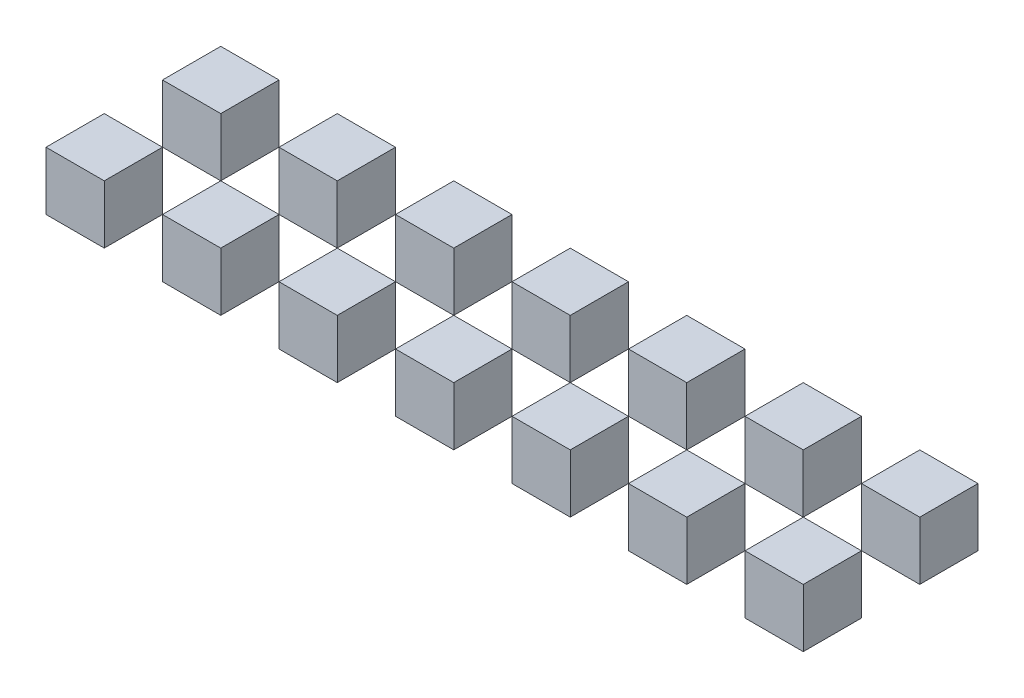
from build123d import *

# Parameters (mm, degrees)
SKETCH1_W              = 25.4
SKETCH1_H              = 25.4
BOSS_EXTRUDE1_DEPTH    = 25.4
BOSS_EXTRUDE1_2_DEPTH  = 25.4
BOSS_EXTRUDE1_3_DEPTH  = 25.4
BOSS_EXTRUDE1_4_DEPTH  = 25.4
BOSS_EXTRUDE1_5_DEPTH  = 25.4
BOSS_EXTRUDE1_6_DEPTH  = 25.4
BOSS_EXTRUDE1_7_DEPTH  = 25.4
BOSS_EXTRUDE1_8_DEPTH  = 25.4
BOSS_EXTRUDE1_9_DEPTH  = 25.4
BOSS_EXTRUDE1_10_DEPTH = 25.4
BOSS_EXTRUDE1_11_DEPTH = 25.4
BOSS_EXTRUDE1_12_DEPTH = 25.4
BOSS_EXTRUDE1_13_DEPTH = 25.4
BOSS_EXTRUDE1_14_DEPTH = 25.4


with BuildPart() as part:
    # Sketch1 → Boss-Extrude1 (new body)
    with BuildSketch(Plane(origin=(0, 0, 0), x_dir=(1, 0, 0), z_dir=(0, 1, 0))):
        with Locations((38.1, 12.7)):
            Rectangle(SKETCH1_W, SKETCH1_H)
    extrude(amount=BOSS_EXTRUDE1_DEPTH)


with BuildPart() as body_2:
    # Sketch1 → Boss-Extrude1 2 (new body)
    with BuildSketch(Plane(origin=(0, 0, 0), x_dir=(1, 0, 0), z_dir=(0, 1, 0))):
        with Locations((-12.7, 12.7)):
            Rectangle(SKETCH1_W, SKETCH1_H)
    extrude(amount=BOSS_EXTRUDE1_2_DEPTH)


with BuildPart() as body_3:
    # Sketch1 → Boss-Extrude1 3 (new body)
    with BuildSketch(Plane(origin=(0, 0, 0), x_dir=(1, 0, 0), z_dir=(0, 1, 0))):
        with Locations((88.9, 12.7)):
            Rectangle(SKETCH1_W, SKETCH1_H)
    extrude(amount=BOSS_EXTRUDE1_3_DEPTH)


with BuildPart() as body_4:
    # Sketch1 → Boss-Extrude1 4 (new body)
    with BuildSketch(Plane(origin=(0, 0, 0), x_dir=(1, 0, 0), z_dir=(0, 1, 0))):
        with Locations((139.7, 12.7)):
            Rectangle(SKETCH1_W, SKETCH1_H)
    extrude(amount=BOSS_EXTRUDE1_4_DEPTH)


with BuildPart() as body_5:
    # Sketch1 → Boss-Extrude1 5 (new body)
    with BuildSketch(Plane(origin=(0, 0, 0), x_dir=(1, 0, 0), z_dir=(0, 1, 0))):
        with Locations((190.5, 12.7)):
            Rectangle(SKETCH1_W, SKETCH1_H)
    extrude(amount=BOSS_EXTRUDE1_5_DEPTH)


with BuildPart() as body_6:
    # Sketch1 → Boss-Extrude1 6 (new body)
    with BuildSketch(Plane(origin=(0, 0, 0), x_dir=(1, 0, 0), z_dir=(0, 1, 0))):
        with Locations((241.3, 12.7)):
            Rectangle(SKETCH1_W, SKETCH1_H)
    extrude(amount=BOSS_EXTRUDE1_6_DEPTH)


with BuildPart() as body_7:
    # Sketch1 → Boss-Extrude1 7 (new body)
    with BuildSketch(Plane(origin=(0, 0, 0), x_dir=(1, 0, 0), z_dir=(0, 1, 0))):
        with Locations((292.1, 12.7)):
            Rectangle(SKETCH1_W, SKETCH1_H)
    extrude(amount=BOSS_EXTRUDE1_7_DEPTH)


with BuildPart() as body_8:
    # Sketch1 → Boss-Extrude1 8 (new body)
    with BuildSketch(Plane(origin=(0, 0, 0), x_dir=(1, 0, 0), z_dir=(0, 1, 0))):
        with Locations((38.1, 63.5)):
            Rectangle(SKETCH1_W, SKETCH1_H)
    extrude(amount=BOSS_EXTRUDE1_8_DEPTH)


with BuildPart() as body_9:
    # Sketch1 → Boss-Extrude1 9 (new body)
    with BuildSketch(Plane(origin=(0, 0, 0), x_dir=(1, 0, 0), z_dir=(0, 1, 0))):
        with Locations((88.9, 63.5)):
            Rectangle(SKETCH1_W, SKETCH1_H)
    extrude(amount=BOSS_EXTRUDE1_9_DEPTH)


with BuildPart() as body_10:
    # Sketch1 → Boss-Extrude1 10 (new body)
    with BuildSketch(Plane(origin=(0, 0, 0), x_dir=(1, 0, 0), z_dir=(0, 1, 0))):
        with Locations((139.7, 63.5)):
            Rectangle(SKETCH1_W, SKETCH1_H)
    extrude(amount=BOSS_EXTRUDE1_10_DEPTH)


with BuildPart() as body_11:
    # Sketch1 → Boss-Extrude1 11 (new body)
    with BuildSketch(Plane(origin=(0, 0, 0), x_dir=(1, 0, 0), z_dir=(0, 1, 0))):
        with Locations((190.5, 63.5)):
            Rectangle(SKETCH1_W, SKETCH1_H)
    extrude(amount=BOSS_EXTRUDE1_11_DEPTH)


with BuildPart() as body_12:
    # Sketch1 → Boss-Extrude1 12 (new body)
    with BuildSketch(Plane(origin=(0, 0, 0), x_dir=(1, 0, 0), z_dir=(0, 1, 0))):
        with Locations((241.3, 63.5)):
            Rectangle(SKETCH1_W, SKETCH1_H)
    extrude(amount=BOSS_EXTRUDE1_12_DEPTH)


with BuildPart() as body_13:
    # Sketch1 → Boss-Extrude1 13 (new body)
    with BuildSketch(Plane(origin=(0, 0, 0), x_dir=(1, 0, 0), z_dir=(0, 1, 0))):
        with Locations((292.1, 63.5)):
            Rectangle(SKETCH1_W, SKETCH1_H)
    extrude(amount=BOSS_EXTRUDE1_13_DEPTH)


with BuildPart() as body_14:
    # Sketch1 → Boss-Extrude1 14 (new body)
    with BuildSketch(Plane(origin=(0, 0, 0), x_dir=(1, 0, 0), z_dir=(0, 1, 0))):
        with Locations((-12.7, 63.5)):
            Rectangle(SKETCH1_W, SKETCH1_H)
    extrude(amount=BOSS_EXTRUDE1_14_DEPTH)


solid = Compound([part.part, body_2.part, body_3.part, body_4.part, body_5.part, body_6.part, body_7.part, body_8.part, body_9.part, body_10.part, body_11.part, body_12.part, body_13.part, body_14.part])
